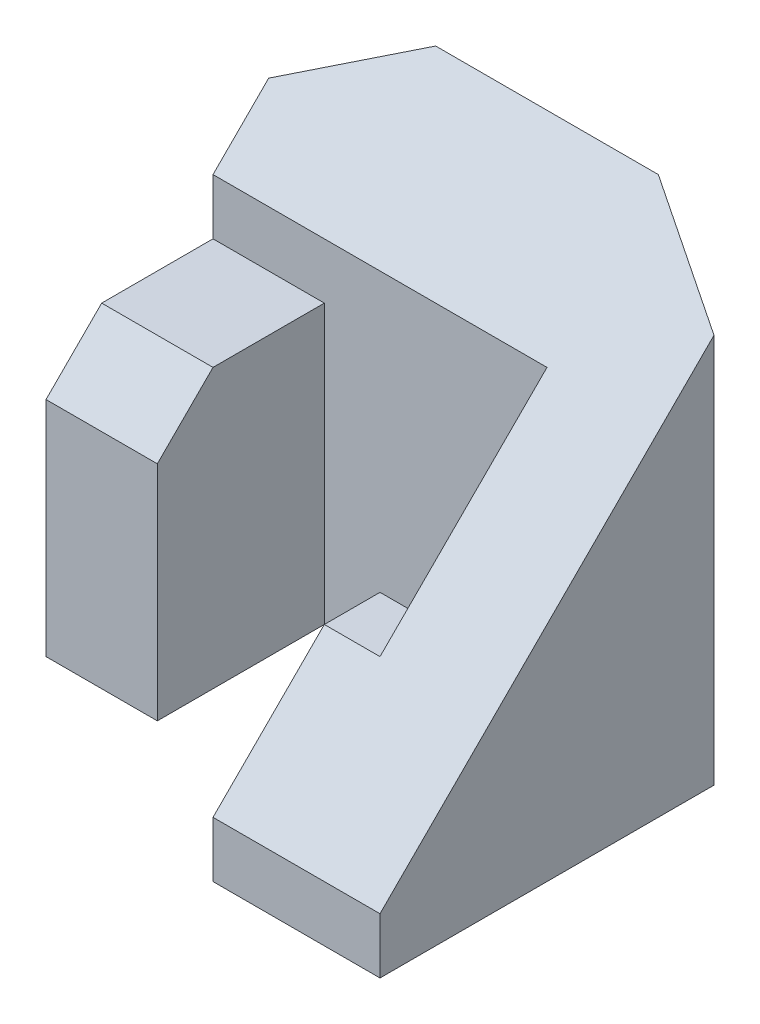
from build123d import *

# Parameters (mm, degrees)
SKETCH1_W           = 40
SKETCH1_H           = 40
BOSS_EXTRUDE1_DEPTH = 35
CUT_EXTRUDE1_DEPTH  = 41
CUT_EXTRUDE3_DEPTH  = 41
CUT_EXTRUDE4_DEPTH  = 5
SKETCH5_W           = 10
SKETCH5_H           = 25
BOSS_EXTRUDE2_DEPTH = 15
CUT_EXTRUDE5_DEPTH  = 15
CUT_EXTRUDE6_DEPTH  = 41


with BuildPart() as part:
    # Sketch1 → Boss-Extrude1 (new body)
    with BuildSketch(Plane.XY):
        Rectangle(SKETCH1_W, SKETCH1_H)
    extrude(amount=BOSS_EXTRUDE1_DEPTH)

    # Sketch2 → Cut-Extrude1 (cut, through all)
    with BuildSketch(Plane(origin=(0, 20, 0), x_dir=(1, 0, 0), z_dir=(0, 1, 0))):
        Polygon((-20, -10), (10, -10), (10, -20), (5, -20), (5, -35), (-20, -35), align=None)
    extrude(amount=-CUT_EXTRUDE1_DEPTH, mode=Mode.SUBTRACT)

    # Sketch3 → Cut-Extrude3 (cut, through all)
    with BuildSketch(Plane(origin=(-20, 0, 0), x_dir=(0, 0, -1), z_dir=(1, 0, 0))):
        Polygon((0, 20), (-35, -15), (-35, 20), align=None)
    extrude(amount=CUT_EXTRUDE3_DEPTH, mode=Mode.SUBTRACT)

    # Sketch4 → Cut-Extrude4 (cut)
    with BuildSketch(Plane.ZY.offset(-5)):
        Polygon((20, 0), (20, -5), (25, -5), align=None)
    extrude(amount=-CUT_EXTRUDE4_DEPTH, mode=Mode.SUBTRACT)

    # Sketch5 → Boss-Extrude2 (add)
    with BuildSketch(Plane.XY.offset(10)):
        with Locations((-15, -7.5)):
            Rectangle(SKETCH5_W, SKETCH5_H)
    extrude(amount=BOSS_EXTRUDE2_DEPTH)

    # Sketch6 → Cut-Extrude5 (cut)
    with BuildSketch(Plane.ZY.offset(20)):
        Polygon((25, 5), (20, 5), (25, 0), align=None)
    extrude(amount=-CUT_EXTRUDE5_DEPTH, mode=Mode.SUBTRACT)

    # Sketch7 → Cut-Extrude6 (cut, through all)
    with BuildSketch(Plane.XZ.offset(20)):
        Polygon((10, 0), (20, 5), (20, 0), align=None)
        Polygon((-20, 0), (-10, 0), (-20, 5), align=None)
    extrude(amount=-CUT_EXTRUDE6_DEPTH, mode=Mode.SUBTRACT)


solid = part.part
